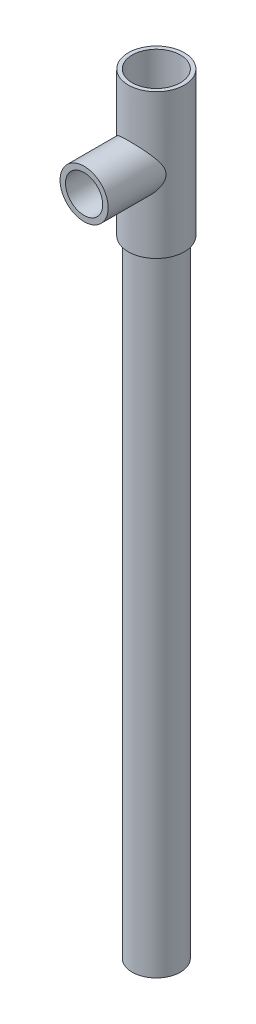
from build123d import *

# Parameters (mm, degrees)
SKETCH1_R                = 12.7
SKETCH1_R_2              = 10.313724198
BOSS_EXTRUDE1_DEPTH      = 355.6
SKETCH2_R                = 14.78033946
SKETCH2_R_2              = 12.713812338
BOSS_EXTRUDE2_DEPTH      = 50.8
BOSS_EXTRUDE2_DEPTH_BACK = 25.4
SKETCH3_R                = 12.7
SKETCH3_R_2              = 9.805342129
BOSS_EXTRUDE3_DEPTH      = 38.1


with BuildPart() as part:
    # Sketch1 → Boss-Extrude1 (new body)
    with BuildSketch(Plane(origin=(0, 0, 0), x_dir=(1, 0, 0), z_dir=(0, 1, 0))):
        Circle(SKETCH1_R)
        Circle(SKETCH1_R_2, mode=Mode.SUBTRACT)
    extrude(amount=BOSS_EXTRUDE1_DEPTH)


with BuildPart() as body_2:
    # Sketch2 → Boss-Extrude2 (new body, two sides)
    with BuildSketch(Plane(origin=(0, 355.6, 0), x_dir=(1, 0, 0), z_dir=(0, 1, 0))) as boss_extrude2_sk:
        Circle(SKETCH2_R)
        Circle(SKETCH2_R_2, mode=Mode.SUBTRACT)
    extrude(amount=BOSS_EXTRUDE2_DEPTH)
    extrude(boss_extrude2_sk.sketch, amount=-BOSS_EXTRUDE2_DEPTH_BACK)

    # Sketch3 → Boss-Extrude3 (add)
    with BuildSketch(Plane.XY):
        with Locations((0, 368.3)):
            Circle(SKETCH3_R)
        with Locations((0, 368.3)):
            Circle(SKETCH3_R_2, mode=Mode.SUBTRACT)
    extrude(amount=BOSS_EXTRUDE3_DEPTH)


solid = Compound([part.part, body_2.part])
